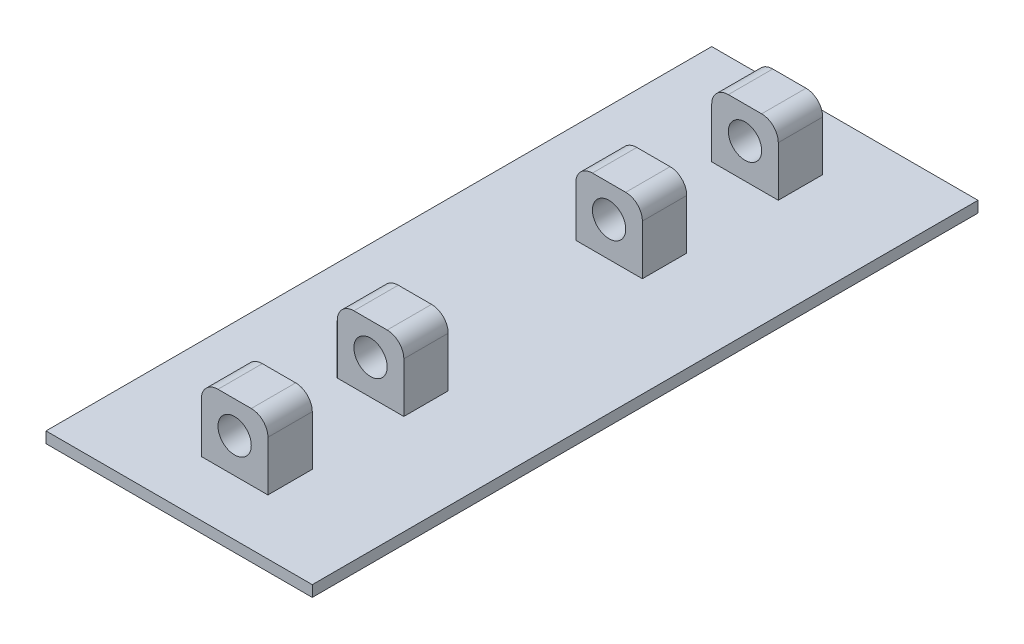
from build123d import *

# Parameters (mm, degrees)
SKETCH1_W               = 240
SKETCH1_H               = 600
EXTRUDE1_DEPTH          = 10
SKETCH2_R               = 15
EXTRUDE2_DEPTH          = 40
MIRROR2_COPY_1_SKETCH_R = 15
MIRROR2_COPY_1_DEPTH    = 40


with BuildPart() as part:
    # Sketch1 → Extrude1 (new body)
    with BuildSketch(Plane(origin=(0, 0, 0), x_dir=(1, 0, 0), z_dir=(0, 1, 0))):
        Rectangle(SKETCH1_W, SKETCH1_H)
    extrude(amount=EXTRUDE1_DEPTH)

    # Sketch2 → Extrude2 (add)
    with BuildSketch(Plane.XY.offset(250)):
        with BuildLine():
            Line((-30, 10), (30, 10))
            Line((30, 10), (30, 55))
            ThreePointArc((30, 55), (25.606601718, 65.606601718), (15, 70))
            Line((15, 70), (-15, 70))
            ThreePointArc((-15, 70), (-25.606601718, 65.606601718), (-30, 55))
            Line((-30, 55), (-30, 10))
        make_face()
        with Locations((0, 41.214252503)):
            Circle(SKETCH2_R, mode=Mode.SUBTRACT)
    extrude2 = extrude(amount=-EXTRUDE2_DEPTH)

    # Mirror1: Extrude2 across plane
    add(extrude2.mirror(Plane.XY.offset(168.75)))

    # Mirror2: Extrude2 across plane
    add(extrude2.mirror(Plane.XY))

    # Mirror2 copy 1 sketch → Mirror2 copy 1 (add)
    with BuildSketch(Plane.XY.offset(-87.5)):
        with BuildLine():
            Line((-30, 10), (30, 10))
            Line((30, 10), (30, 55))
            ThreePointArc((30, 55), (25.606601718, 65.606601718), (15, 70))
            Line((15, 70), (-15, 70))
            ThreePointArc((-15, 70), (-25.606601718, 65.606601718), (-30, 55))
            Line((-30, 55), (-30, 10))
        make_face()
        with Locations((0, 41.214252503)):
            Circle(MIRROR2_COPY_1_SKETCH_R, mode=Mode.SUBTRACT)
    extrude(amount=-MIRROR2_COPY_1_DEPTH)


solid = part.part
